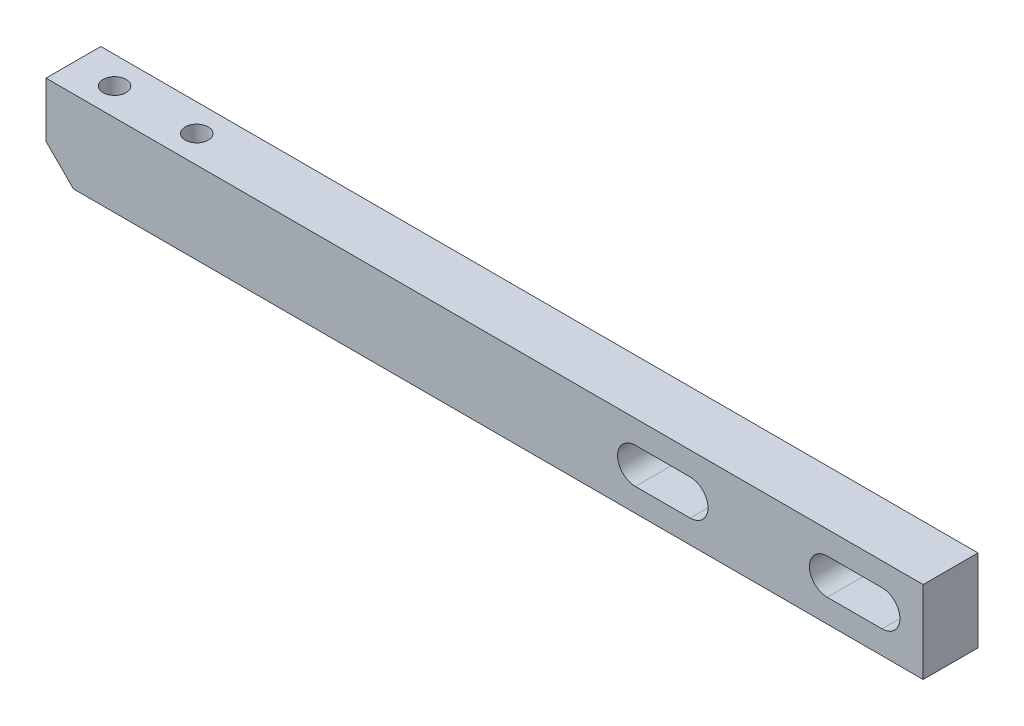
from build123d import *

# Parameters (mm, degrees)
SKETCH_1_W             = 160
SKETCH_1_H             = 15
EXTRUDE_1_DEPTH        = 10
HOLE_WIZARD_M5_1_D     = 4.2
HOLE_WIZARD_M5_1_DEPTH = 13
HOLE_WIZARD_M5_1_TIP   = 1.2618073
CHAMFER_1_SIZE         = 5
CUT_EXTRUDE_1_DEPTH    = 10


with BuildPart() as part:
    # 草图1 → 凸台-拉伸1 (new body)
    with BuildSketch(Plane.XY):
        with Locations((80, 7.5)):
            Rectangle(SKETCH_1_W, SKETCH_1_H)
    extrude(amount=EXTRUDE_1_DEPTH)

    # M5 螺纹孔1
    with Locations(Plane(origin=(7.5, 15, 5), x_dir=(0, 0, 1), z_dir=(0, 1, 0))):
        with Locations((0, 0), (0, 15)):
            Hole(HOLE_WIZARD_M5_1_D / 2, depth=HOLE_WIZARD_M5_1_DEPTH)
            with Locations((0, 0, -(HOLE_WIZARD_M5_1_DEPTH + HOLE_WIZARD_M5_1_TIP / 2))):  # 118° drill point
                Cone(0, HOLE_WIZARD_M5_1_D / 2, HOLE_WIZARD_M5_1_TIP, mode=Mode.SUBTRACT)

    # 倒角1
    chamfer_1_edges = [part.edges().sort_by_distance(p)[0] for p in [
        (0, 0, 5),
    ]]
    chamfer(chamfer_1_edges, length=CHAMFER_1_SIZE)

    # 草图4 → 切除-拉伸1 (cut)
    with BuildSketch(Plane(origin=(0, 0, 0), x_dir=(-1, 0, 0), z_dir=(0, 0, -1))):
        with BuildLine():
            Line((-152.5, 10.75), (-142.5, 10.75))
            ThreePointArc((-142.5, 10.75), (-139.25, 7.5), (-142.5, 4.25))
            Line((-142.5, 4.25), (-152.5, 4.25))
            ThreePointArc((-152.5, 4.25), (-155.75, 7.5), (-152.5, 10.75))
        make_face()
        with BuildLine():
            Line((-117.5, 10.75), (-107.5, 10.75))
            ThreePointArc((-107.5, 10.75), (-104.25, 7.5), (-107.5, 4.25))
            Line((-107.5, 4.25), (-117.5, 4.25))
            ThreePointArc((-117.5, 4.25), (-120.75, 7.5), (-117.5, 10.75))
        make_face()
    extrude(amount=-CUT_EXTRUDE_1_DEPTH, mode=Mode.SUBTRACT)


solid = part.part
